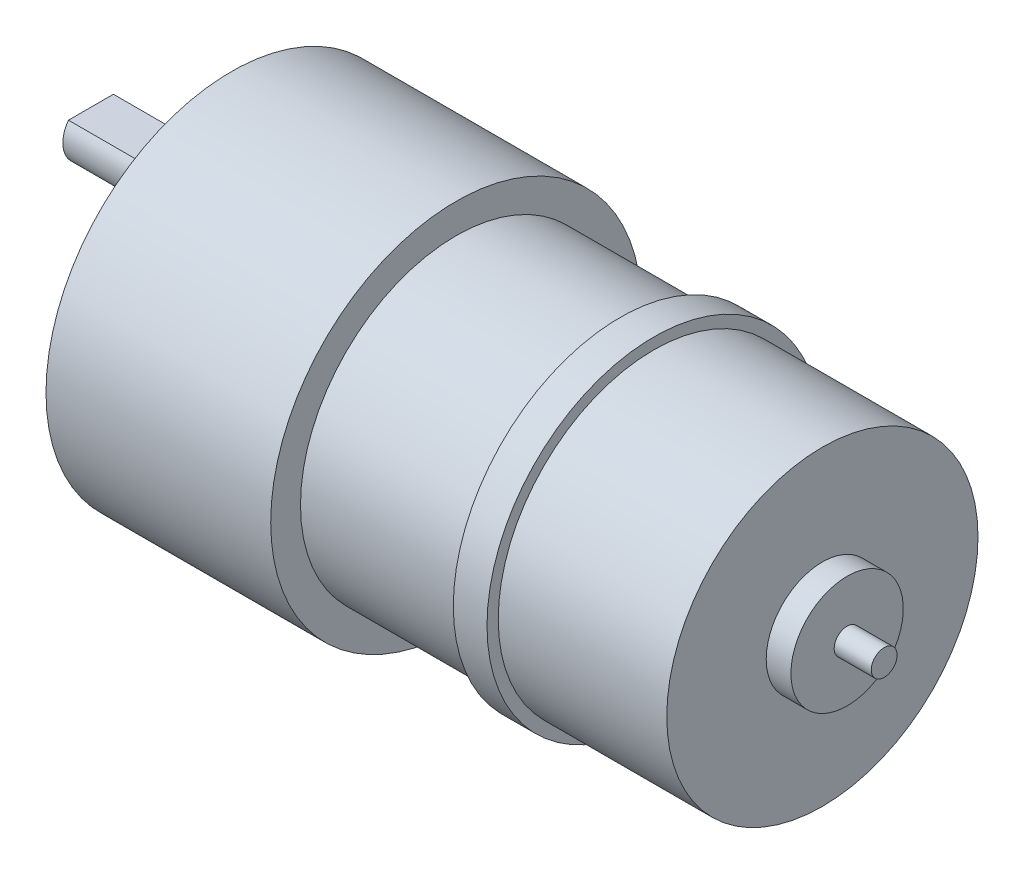
from build123d import *

# Parameters (mm, degrees)
SKETCH1_W          = 20
SKETCH1_H          = 16.5
SKETCH1_W_2        = 14.6
SKETCH1_H_2        = 13.85
SKETCH1_W_3        = 3
SKETCH1_H_3        = 1
SKETCH1_W_4        = 3.3
SKETCH1_H_4        = 1.15
SKETCH3_W          = 10.5
SKETCH3_H          = 2.5
CUT_EXTRUDE1_DEPTH = 8


with BuildPart() as part:
    # Sketch1 → Revolve1 (revolve)
    with BuildSketch(Plane.XY):
        with Locations((10, 8.25)):
            Rectangle(SKETCH1_W, SKETCH1_H)
        with Locations((27.3, 6.925)):
            Rectangle(SKETCH1_W_2, SKETCH1_H_2)
        with Locations((36.1, 6.925)):
            Rectangle(SKETCH1_W_3, SKETCH1_H_2)
        with Locations((36.1, 14.35)):
            Rectangle(SKETCH1_W_3, SKETCH1_H_3)
        Polygon((37.6, 13.85), (37.6, 0), (52.6, 0), (52.6, 5), (52.6, 13.85), align=None)
        Polygon((52.6, 5), (52.6, 0), (54.8, 0), (54.8, 1.15), (54.8, 5), align=None)
        with Locations((56.45, 0.575)):
            Rectangle(SKETCH1_W_4, SKETCH1_H_4)
    revolve(axis=Axis((0, 0, 0), (1, 0, 0)))

    # Sketch3 → Revolve2 (revolve)
    with BuildSketch(Plane.XY):
        with Locations((-7.25, 7.25)):
            Rectangle(SKETCH3_W, SKETCH3_H)
        Polygon((-2, 8.5), (-2, 6), (0, 6), (0, 11), (-2, 11), align=None)
    revolve(axis=Axis((-12.5, 6, 0), (1, 0, 0)))

    # Sketch4 → Cut-Extrude1 (cut)
    with BuildSketch(Plane.ZY.offset(12.5)):
        Polygon((-72.605280298, 7.5), (-2, 7.5), (2, 7.5), (72.605280298, 7.5), (72.605280298, 148.710560596), (-72.605280298, 148.710560596), align=None)
    extrude(amount=-CUT_EXTRUDE1_DEPTH, mode=Mode.SUBTRACT)


solid = part.part
